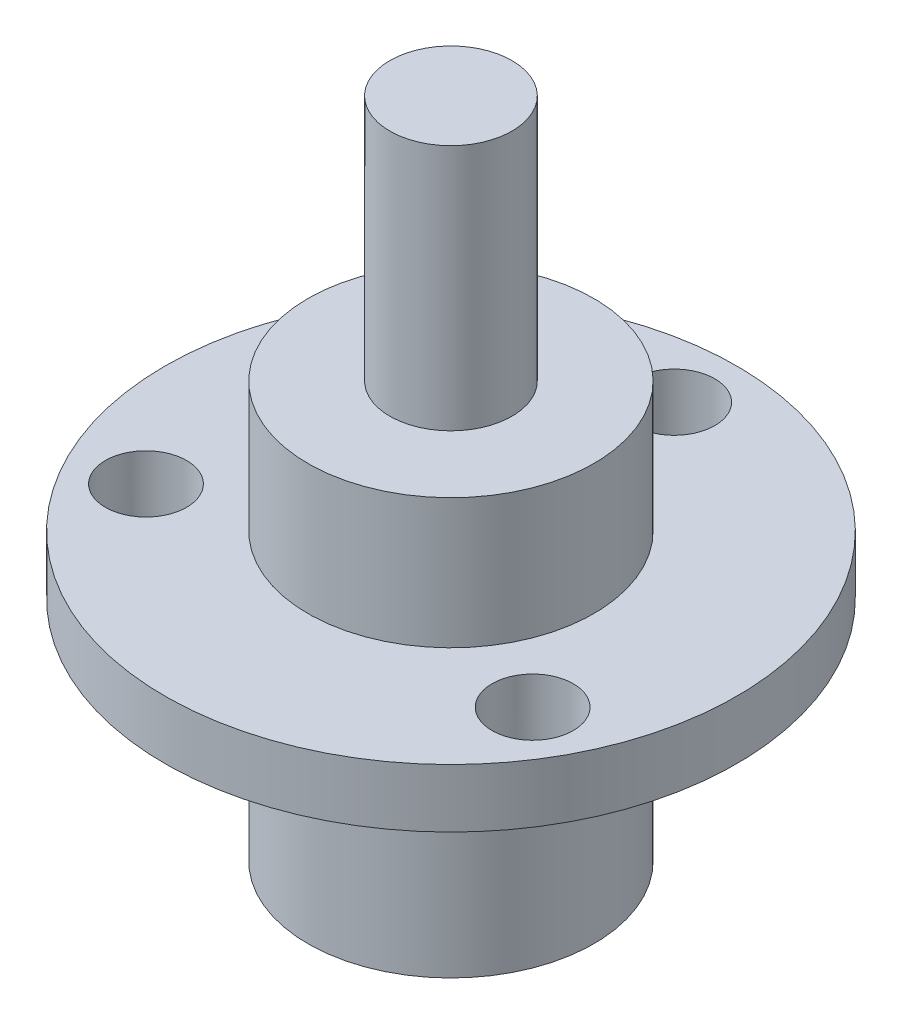
from build123d import *

# Parameters (mm, degrees)
SKETCH2_R          = 1.5875
CUT_EXTRUDE1_DEPTH = 12.176
CIRPATTERN1_COUNT  = 3


with BuildPart() as part:
    # Sketch1 → Revolve1 (revolve)
    with BuildSketch(Plane.XY):
        Polygon((-5.588, 0), (-5.588, 8.89), (-11.176, 8.89), (-11.176, 11.176), (-5.588, 11.176), (-5.588, 16.256), (-2.3876, 16.256), (-2.3876, 25.908), (0, 25.908), (0, 0), align=None)
    revolve(axis=Axis((0, 25.908, 0), (0, -1, 0)))

    # Sketch2 → Cut-Extrude1 (cut, through all)
    with BuildSketch(Plane(origin=(0, 11.176, 0), x_dir=(1, 0, 0), z_dir=(0, 1, 0))):
        with Locations((0, 8.7249)):
            Circle(SKETCH2_R)
    cut_extrude1 = extrude(amount=-CUT_EXTRUDE1_DEPTH, mode=Mode.SUBTRACT)

    # CirPattern1: Cut-Extrude1 ×3 about axis
    cirpattern1_axis = Axis((0, 0, 0), (0, 1, 0))
    for i in range(1, CIRPATTERN1_COUNT):
        add(cut_extrude1.rotate(cirpattern1_axis, i * 360 / CIRPATTERN1_COUNT), mode=Mode.SUBTRACT)


solid = part.part
